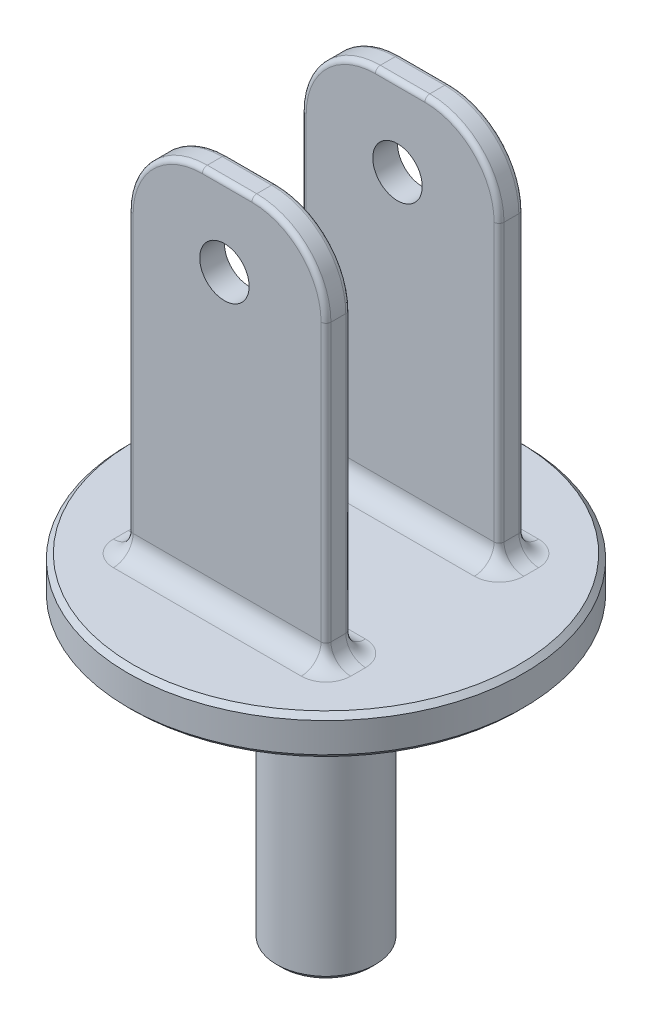
from build123d import *

# Parameters (mm, degrees)
SKETCH2_R            = 40
BOSS_EXTRUDE1_DEPTH  = 8
SKETCH6_R            = 10
SKETCH6_R_2          = 7.5
BOSS_EXTRUDE4_DEPTH  = 60
CHAMFER1_SIZE        = 1
SKETCH19_W           = 40
SKETCH19_H           = 5
BOSS_EXTRUDE5_DEPTH  = 75
FILLET1_R            = 15
FILLET2_R            = 1
FILLET3_R            = 4
FILLET1_OF_MIRROR2_R = 15
FILLET2_OF_MIRROR2_R = 1
FILLET3_OF_MIRROR2_R = 4
SKETCH21_R           = 5
CUT_EXTRUDE1_DEPTH   = 40


with BuildPart() as part:
    # Sketch2 → Boss-Extrude1 (new body)
    with BuildSketch(Plane(origin=(0, 0, 0), x_dir=(1, 0, 0), z_dir=(0, 1, 0))):
        Circle(SKETCH2_R)
    extrude(amount=BOSS_EXTRUDE1_DEPTH)

    # Sketch6 → Boss-Extrude4 (add)
    with BuildSketch(Plane.XZ):
        Circle(SKETCH6_R)
        Circle(SKETCH6_R_2, mode=Mode.SUBTRACT)
    extrude(amount=BOSS_EXTRUDE4_DEPTH)

    # Chamfer1
    chamfer1_edges = [part.edges().sort_by_distance(p)[0] for p in [
        (-40, 0, 0),
        (-40, 8, 0),
        (-10, -60, 0),
    ]]
    chamfer(chamfer1_edges, length=CHAMFER1_SIZE)

    # Sketch19 → Boss-Extrude5 (add)
    with BuildSketch(Plane(origin=(0, 8, 0), x_dir=(1, 0, 0), z_dir=(0, 1, 0))):
        with Locations((0, 17.5)):
            Rectangle(SKETCH19_W, SKETCH19_H)
    boss_extrude5 = extrude(amount=BOSS_EXTRUDE5_DEPTH)

    # Fillet1
    fillet1_edges = [part.edges().sort_by_distance(p)[0] for p in [
        (-20, 83, -17.5),
        (20, 83, -17.5),
    ]]
    fillet(fillet1_edges, radius=FILLET1_R)

    # Fillet2
    fillet2_edges = [part.edges().sort_by_distance(p)[0] for p in [
        (0, 83, -15),
        (0, 83, -20),
        (-20, 38, -20),
        (20, 38, -20),
        (-15.606601718, 78.606601718, -20),
        (15.606601718, 78.606601718, -20),
        (20, 38, -15),
        (-20, 38, -15),
        (-15.606601718, 78.606601718, -15),
        (15.606601718, 78.606601718, -15),
    ]]
    fillet(fillet2_edges, radius=FILLET2_R)

    # Fillet3
    fillet3_edges = [part.edges().sort_by_distance(p)[0] for p in [
        (0, 8, -20),
        (20, 8, -17.5),
        (0, 8, -15),
        (-20, 8, -17.5),
        (19.707106781, 8, -19.707106781),
        (19.707106781, 8, -15.292893219),
        (-19.707106781, 8, -19.707106781),
        (-19.707106781, 8, -15.292893219),
    ]]
    fillet(fillet3_edges, radius=FILLET3_R)

    # Mirror2: Boss-Extrude5 across plane
    add(boss_extrude5.mirror(Plane.XY))

    # Fillet1 of Mirror2
    fillet1_of_mirror2_edges = [part.edges().sort_by_distance(p)[0] for p in [
        (-20, 83, 17.5),
        (20, 83, 17.5),
    ]]
    fillet(fillet1_of_mirror2_edges, radius=FILLET1_OF_MIRROR2_R)

    # Fillet2 of Mirror2
    fillet2_of_mirror2_edges = [part.edges().sort_by_distance(p)[0] for p in [
        (0, 83, 15),
        (0, 83, 20),
        (-20, 38, 20),
        (20, 38, 20),
        (-15.606601718, 78.606601718, 20),
        (15.606601718, 78.606601718, 20),
        (20, 38, 15),
        (-20, 38, 15),
        (-15.606601718, 78.606601718, 15),
        (15.606601718, 78.606601718, 15),
    ]]
    fillet(fillet2_of_mirror2_edges, radius=FILLET2_OF_MIRROR2_R)

    # Fillet3 of Mirror2
    fillet3_of_mirror2_edges = [part.edges().sort_by_distance(p)[0] for p in [
        (0, 8, 20),
        (20, 8, 17.5),
        (0, 8, 15),
        (-20, 8, 17.5),
        (19.707106781, 8, 19.707106781),
        (19.707106781, 8, 15.292893219),
        (-19.707106781, 8, 19.707106781),
        (-19.707106781, 8, 15.292893219),
    ]]
    fillet(fillet3_of_mirror2_edges, radius=FILLET3_OF_MIRROR2_R)

    # Sketch21 → Cut-Extrude1 (cut)
    with BuildSketch(Plane.XY.offset(20)):
        with Locations((-0.54, 67)):
            Circle(SKETCH21_R)
    extrude(amount=-CUT_EXTRUDE1_DEPTH, mode=Mode.SUBTRACT)


solid = part.part
